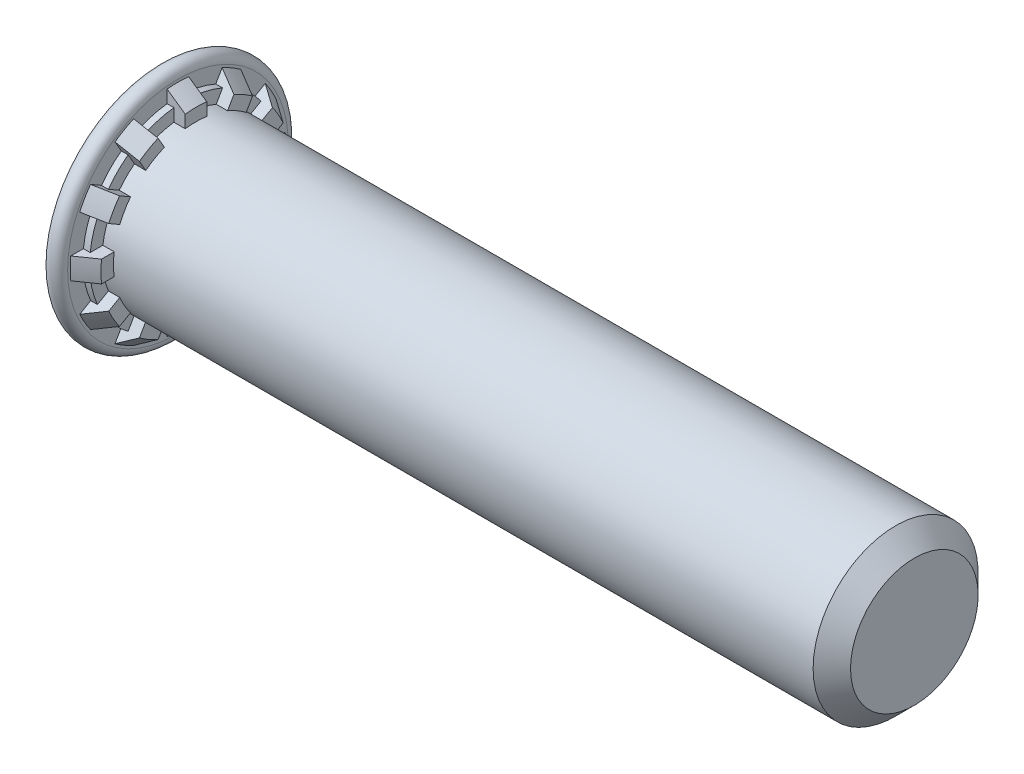
from build123d import *

# Parameters (mm, degrees)
RIBCUT1_DEPTH    = 0.28575
RIBCUT2_DEPTH    = 0.4572
RIBCUTSPAT_COUNT = 12
RIBCUTSPAT_ANGLE = 330


with BuildPart() as part:
    # BodySke → BaseBody (revolve)
    with BuildSketch(Plane.XY):
        with BuildLine():
            Line((0, 0), (0, 2.77876))
            Line((0, 2.77876), (0.00508, 2.77876))
            Line((0.00508, 2.77876), (0.00508, 2.78384))
            ThreePointArc((0.00508, 2.78384), (0.23114, 3.0099), (0.4572, 2.78384))
            Line((0.4572, 2.78384), (0.4572, 2.7178))
            Line((0.4572, 2.7178), (0.9144, 2.4003))
            Line((0.9144, 2.4003), (0.9144, 2.0828))
            Line((0.9144, 2.0828), (18.57756, 2.0828))
            Line((18.57756, 2.0828), (19.05, 1.61036))
            Line((19.05, 1.61036), (19.05, 0))
            Line((19.05, 0), (0, 0))
        make_face()
    revolve(axis=Axis((0, 0, 0), (1, 0, 0)))

    # RibCut1Ske → RibCut1 (cut)
    with BuildSketch(Plane(origin=(0.9144, 0, 0), x_dir=(0, 0, -1), z_dir=(1, 0, 0))):
        with BuildLine():
            Line((0.271859953, 2.064981357), (0.271859953, 2.997597401))
            ThreePointArc((0.271859953, 2.997597401), (0.779019444, 2.907340145), (1.263361075, 2.731925476))
            Line((1.263361075, 2.731925476), (0.797053053, 1.92425629))
            ThreePointArc((0.797053053, 1.92425629), (0.539068307, 2.011830311), (0.271859953, 2.064981357))
        make_face()
    ribcut1 = extrude(amount=-RIBCUT1_DEPTH, mode=Mode.SUBTRACT)

    # RibCut2Ske → RibCut2 (cut)
    with BuildSketch(Plane(origin=(0.9144, 0, 0), x_dir=(0, 0, -1), z_dir=(1, 0, 0))):
        with BuildLine():
            Line((0.271859953, 2.384854766), (0.271859953, 2.997597401))
            ThreePointArc((0.271859953, 2.997597401), (0.779019444, 2.907340145), (1.263361075, 2.731925476))
            Line((1.263361075, 2.731925476), (0.956989757, 2.201274788))
            ThreePointArc((0.956989757, 2.201274788), (0.621243354, 2.318511761), (0.271859953, 2.384854766))
        make_face()
    ribcut2 = extrude(amount=-RIBCUT2_DEPTH, mode=Mode.SUBTRACT)

    # RibCutsPat: RibCut1, RibCut2 ×12 about axis
    ribcutspat_axis = Axis((0, 0, 0), (1, 0, 0))
    for i in range(1, RIBCUTSPAT_COUNT):
        add(ribcut1.rotate(ribcutspat_axis, i * RIBCUTSPAT_ANGLE / (RIBCUTSPAT_COUNT - 1)), mode=Mode.SUBTRACT)
        add(ribcut2.rotate(ribcutspat_axis, i * RIBCUTSPAT_ANGLE / (RIBCUTSPAT_COUNT - 1)), mode=Mode.SUBTRACT)


solid = part.part
